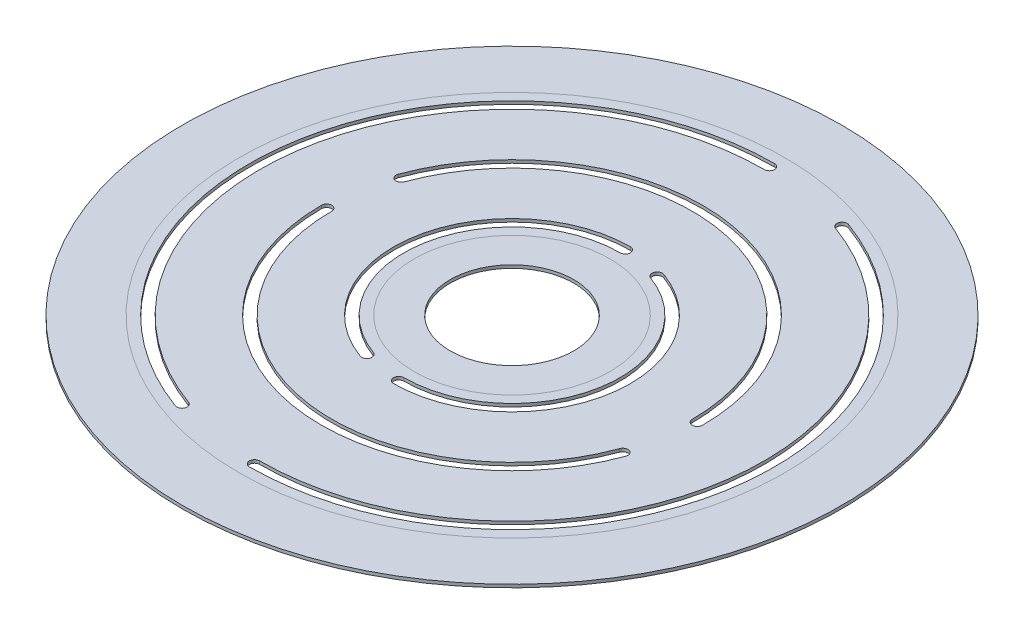
from build123d import *

# Parameters (mm, degrees)
SKETCH1_R           = 32
SKETCH1_R_2         = 6
BOSS_EXTRUDE1_DEPTH = 0.3


with BuildPart() as part:
    # Sketch1 → Boss-Extrude1 (new body)
    with BuildSketch(Plane(origin=(0, 0, 0), x_dir=(1, 0, 0), z_dir=(0, 1, 0))):
        Circle(SKETCH1_R)
        Circle(SKETCH1_R_2, mode=Mode.SUBTRACT)
        with BuildLine():
            ThreePointArc((0, 25.5), (-25.112597702, 4.428028531), (-8.721513655, -23.96216183))
            ThreePointArc((-8.721513655, -23.96216183), (-8.080657273, -23.663325591), (-8.379493511, -23.022469209))
            ThreePointArc((-8.379493511, -23.022469209), (-24.127789949, 4.254380353), (0, 24.5))
            ThreePointArc((0, 24.5), (0.5, 25), (0, 25.5))
        make_face(mode=Mode.SUBTRACT)
        with BuildLine():
            ThreePointArc((18.5, 0), (3.212491287, 18.218943431), (-17.384313485, 6.327372652))
            ThreePointArc((-17.384313485, 6.327372652), (-17.085477246, 5.686516269), (-16.444620864, 5.985352508))
            ThreePointArc((-16.444620864, 5.985352508), (3.038843109, 17.234135678), (17.5, 0))
            ThreePointArc((17.5, 0), (18, -0.5), (18.5, 0))
        make_face(mode=Mode.SUBTRACT)
        with BuildLine():
            ThreePointArc((0, -25.5), (25.112597702, -4.428028531), (8.721513655, 23.96216183))
            ThreePointArc((8.721513655, 23.96216183), (8.080657273, 23.663325591), (8.379493511, 23.022469209))
            ThreePointArc((8.379493511, 23.022469209), (24.127789949, -4.254380353), (0, -24.5))
            ThreePointArc((0, -24.5), (-0.5, -25), (0, -25.5))
        make_face(mode=Mode.SUBTRACT)
        with BuildLine():
            ThreePointArc((0, 11.5), (-11.32528916, 1.996954043), (-3.933231648, -10.806465139))
            ThreePointArc((-3.933231648, -10.806465139), (-3.292375266, -10.5076289), (-3.591211505, -9.866772518))
            ThreePointArc((-3.591211505, -9.866772518), (-10.340481407, 1.823305866), (0, 10.5))
            ThreePointArc((0, 10.5), (0.5, 11), (0, 11.5))
        make_face(mode=Mode.SUBTRACT)
        with BuildLine():
            ThreePointArc((0, -11.5), (11.32528916, -1.996954043), (3.933231648, 10.806465139))
            ThreePointArc((3.933231648, 10.806465139), (3.292375266, 10.5076289), (3.591211505, 9.866772518))
            ThreePointArc((3.591211505, 9.866772518), (10.340481407, -1.823305866), (0, -10.5))
            ThreePointArc((0, -10.5), (-0.5, -11), (0, -11.5))
        make_face(mode=Mode.SUBTRACT)
        with BuildLine():
            ThreePointArc((-18.5, 0), (-3.212491287, -18.218943431), (17.384313485, -6.327372652))
            ThreePointArc((17.384313485, -6.327372652), (17.085477246, -5.686516269), (16.444620864, -5.985352508))
            ThreePointArc((16.444620864, -5.985352508), (-3.038843109, -17.234135678), (-17.5, 0))
            ThreePointArc((-17.5, 0), (-18, 0.5), (-18.5, 0))
        make_face(mode=Mode.SUBTRACT)
    extrude(amount=BOSS_EXTRUDE1_DEPTH)


solid = part.part
